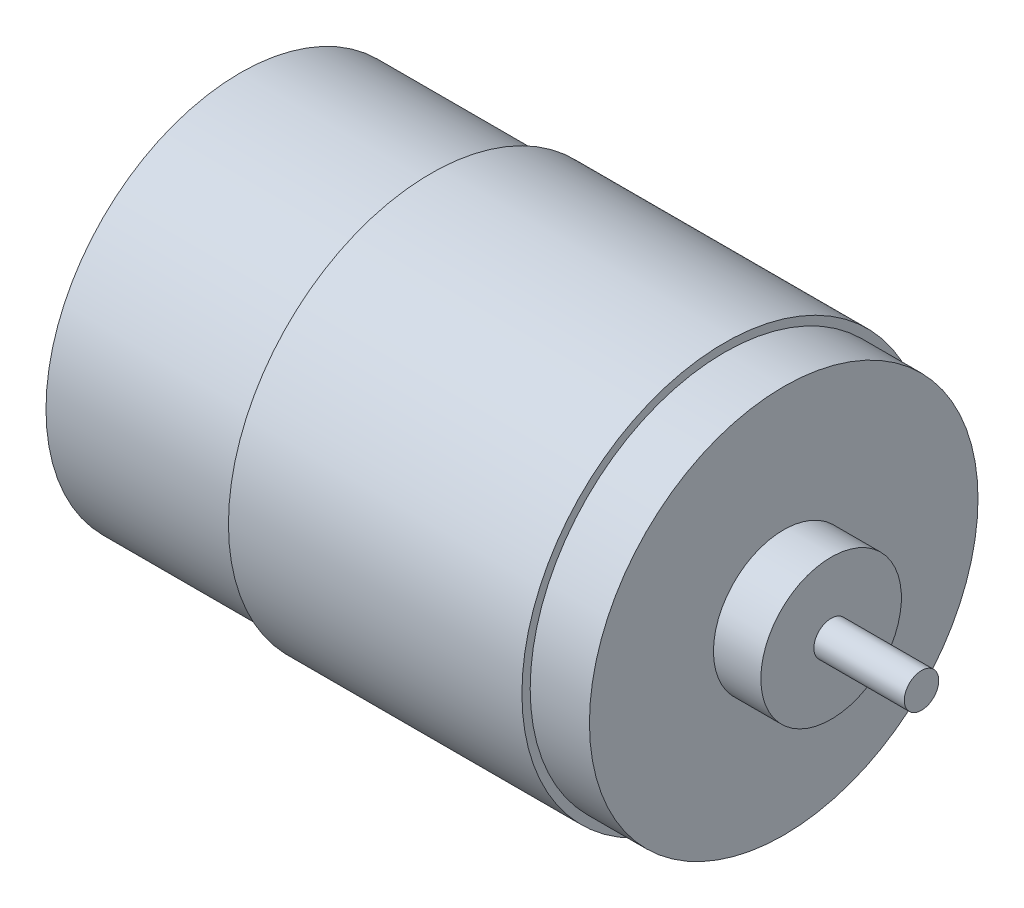
from build123d import *


with BuildPart() as part:
    # Sketch1 → Revolve1 (revolve)
    with BuildSketch(Plane.XY):
        Polygon((-29.804083682, 0), (-29.804083682, 1.534627615), (-28.915615063, 1.534627615), (-28.915615063, 2.665405858), (-27.623297071, 2.665405858), (-27.623297071, 4.765422594), (-26.694443515, 5.694276151), (-24.647883682, 5.694276151), (-24.647883682, 17.907), (-7.071083682, 17.907), (-7.071083682, 18.669), (19.979916318, 18.669), (19.979916318, 17.907), (25.440916318, 17.907), (25.440916318, 6.477), (29.809716318, 6.477), (29.809716318, 1.5875), (38.140916318, 1.5875), (38.140916318, 0), align=None)
    revolve(axis=Axis((-37.638761506, 0, 0), (1, 0, 0)))


solid = part.part
